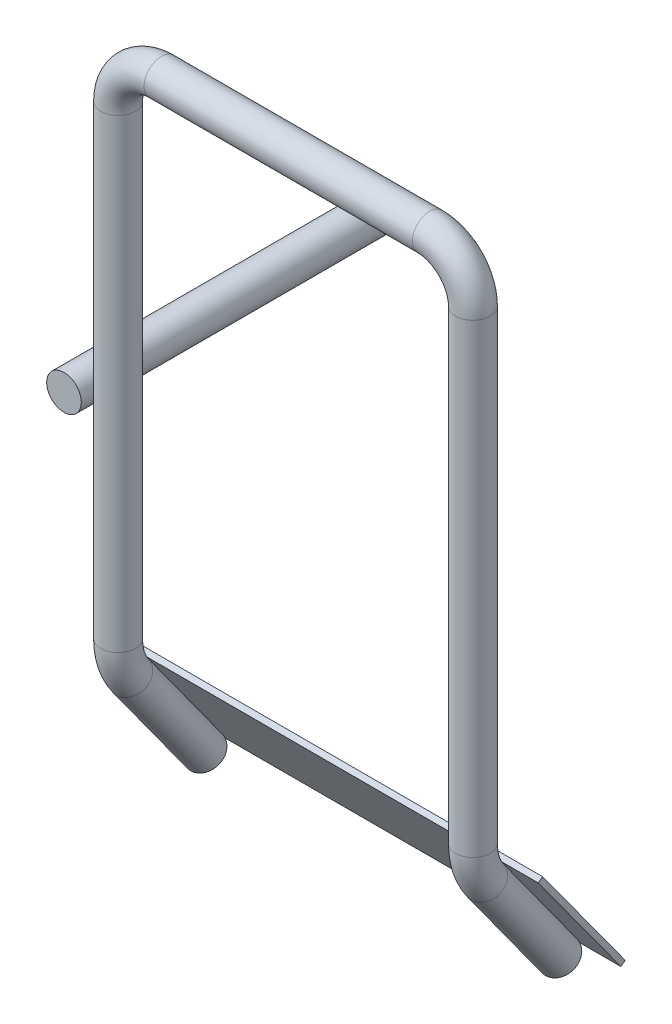
from build123d import *

# Parameters (mm, degrees)
SKETCH2_R                = 0.8
EXTRUDE1_DEPTH           = 5
EXTRUDE1_DEPTH_BACK      = 10
SKETCH3_R                = 0.8
EXTRUDE_THIN1_DEPTH      = 10
EXTRUDE_THIN1_DEPTH_BACK = 10


with BuildPart() as part:
    # Sweep1: sweep along a curve in space
    with BuildLine() as sweep1_path:
        Line((8.2, 0, 17), (8.2, 4.741455494, 20.430539286))
        ThreePointArc((8.2, 4.741455494, 20.430539286), (8.2, 5.575775422, 20.854086356), (8.2, 6.5, 21))
        Line((8.2, 6.5, 21), (8.2, 28, 21))
        ThreePointArc((8.2, 28, 21), (7.614213562, 29.414213562, 21), (6.2, 30, 21))
        Line((6.2, 30, 21), (-6.2, 30, 21))
        ThreePointArc((-8.2, 28, 21), (-7.614213562, 29.414213562, 21), (-6.2, 30, 21))
        Line((-8.2, 28, 21), (-8.2, 6.5, 21))
        ThreePointArc((-8.2, 6.5, 21), (-8.2, 5.575775422, 20.854086356), (-8.2, 4.741455494, 20.430539286))
        Line((-8.2, 4.741455494, 20.430539286), (-8.2, 0, 17))
    # Sketch2 → Sweep1 (sweep)
    with BuildSketch(Plane(origin=(8.2, 0, 17), x_dir=(-1, 0, 0), z_dir=(0, 0.810179762077197, 0.586181501858031))):
        Circle(SKETCH2_R)
    sweep(path=sweep1_path.line)

    # Sketch3 → Extrude1 (add, two sides: drawn at the far end of the back side and taken through both)
    with BuildSketch(Plane.XY.offset(17).offset(-EXTRUDE1_DEPTH_BACK)):
        with Locations((-9.7, 16.100381126)):
            Circle(SKETCH3_R)
    extrude(amount=EXTRUDE1_DEPTH + EXTRUDE1_DEPTH_BACK)


with BuildPart() as body_2:
    # Sketch4 → Extrude-Thin1 (new, two sides: drawn at the far end of the back side and taken through both)
    with BuildSketch(Plane(origin=(0, 0, 0), x_dir=(0, 0, -1), z_dir=(1, 0, 0)).offset(-EXTRUDE_THIN1_DEPTH_BACK)):
        Polygon((-19.782395477, 5.210400696), (-15.961791337, -0.048209768), (-15.759537088, 0.098736546), (-19.580141228, 5.357347009), align=None)
    extrude(amount=EXTRUDE_THIN1_DEPTH + EXTRUDE_THIN1_DEPTH_BACK)


solid = Compound([part.part, body_2.part])
